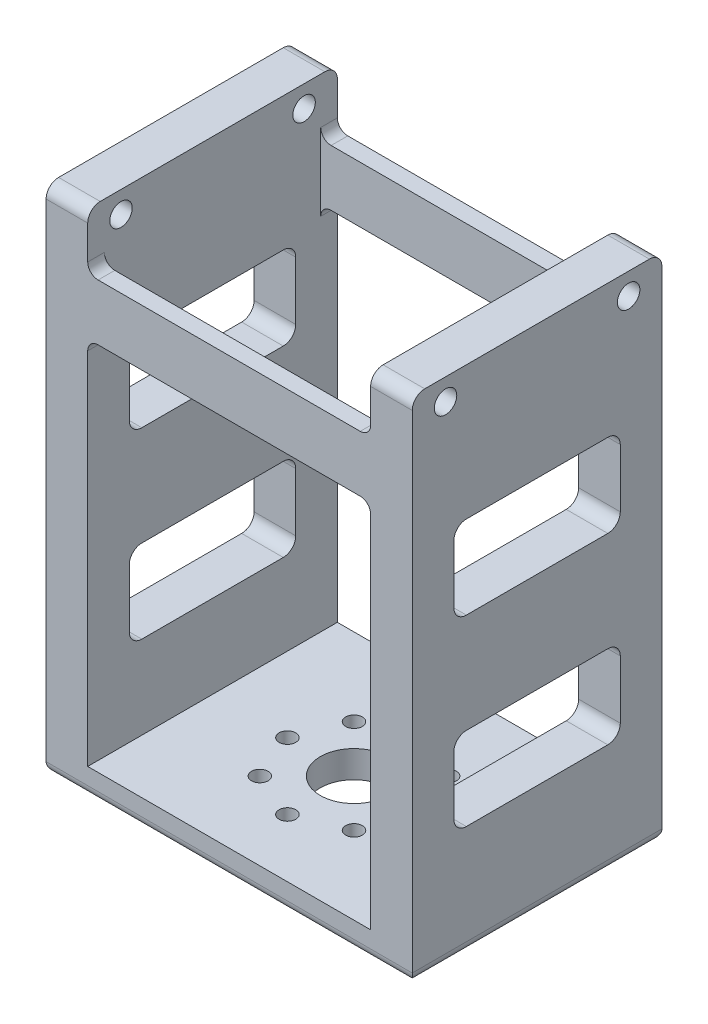
from build123d import *

# Parameters (mm, degrees)
SKETCH1_W            = 44
SKETCH1_H            = 30
BOSS_EXTRUDE1_DEPTH  = 54.5
SKETCH5_W            = 5
SKETCH5_H            = 30
BOSS_EXTRUDE3_DEPTH  = 6.8
SKETCH9_R            = 1.35
CUT_EXTRUDE6_DEPTH   = 79.604643629
FILLET1_R            = 1.5
FILLET2_R            = 1.25
SKETCH11_W           = 34
SKETCH11_H           = 26
CUT_EXTRUDE7_DEPTH   = 51.25
CUT_EXTRUDE8_REACH   = 83.202
SKETCH13_R           = 4.05
SKETCH13_R_2         = 1
CIRPATTERN1_COUNT    = 8
CUT_EXTRUDE10_REACH  = 83.202
SKETCH15_W           = 20
SKETCH15_H           = 10
FILLET6_R            = 1.5
FILLET6_OF_MIRROR4_R = 1.5
CUT_EXTRUDE11_REACH  = 83.202
SKETCH16_W           = 34
SKETCH16_H           = 44.5
FILLET7_R            = 1.25


with BuildPart() as part:
    # Sketch1 → Boss-Extrude1 (new body)
    with BuildSketch(Plane(origin=(0, 0, 0), x_dir=(1, 0, 0), z_dir=(0, 1, 0))):
        with Locations((22, 15)):
            Rectangle(SKETCH1_W, SKETCH1_H)
    extrude(amount=BOSS_EXTRUDE1_DEPTH)

    # Sketch5 → Boss-Extrude3 (add)
    with BuildSketch(Plane(origin=(0, 54.5, 0), x_dir=(1, 0, 0), z_dir=(0, 1, 0))):
        with Locations((2.5, 15)):
            Rectangle(SKETCH5_W, SKETCH5_H)
    boss_extrude3 = extrude(amount=BOSS_EXTRUDE3_DEPTH)

    # Sketch9 → Cut-Extrude6 (cut, through all)
    with BuildSketch(Plane(origin=(5, 0, 0), x_dir=(0, 0, -1), z_dir=(1, 0, 0))):
        with Locations((26, 58.7)):
            Circle(SKETCH9_R)
        with Locations((4, 58.7)):
            Circle(SKETCH9_R)
    cut_extrude6 = extrude(amount=-CUT_EXTRUDE6_DEPTH, mode=Mode.SUBTRACT)

    # Mirror2: Boss-Extrude3, Cut-Extrude6 across plane
    add(boss_extrude3.mirror(Plane.ZY.offset(-22)))
    add(cut_extrude6.mirror(Plane.ZY.offset(-22)), mode=Mode.SUBTRACT)

    # Fillet1
    fillet1_edges = [part.edges().sort_by_distance(p)[0] for p in [
        (41.5, 61.3, -30),
        (2.5, 61.3, -30),
        (2.5, 61.3, 0),
        (41.5, 61.3, 0),
    ]]
    fillet(fillet1_edges, radius=FILLET1_R)

    # Fillet2
    fillet2_edges = [part.edges().sort_by_distance(p)[0] for p in [
        (0, 0, -15),
        (22, 0, -30),
        (22, 0, 0),
        (44, 0, -15),
    ]]
    fillet(fillet2_edges, radius=FILLET2_R)

    # Sketch11 → Cut-Extrude7 (cut)
    with BuildSketch(Plane(origin=(0, 54.5, 0), x_dir=(1, 0, 0), z_dir=(0, 1, 0))):
        with Locations((22, 15)):
            Rectangle(SKETCH11_W, SKETCH11_H)
    extrude(amount=-CUT_EXTRUDE7_DEPTH, mode=Mode.SUBTRACT)

    # Sketch13 → Cut-Extrude8 (cut, up to next)
    with BuildSketch(Plane.XZ, mode=Mode.PRIVATE) as cut_extrude8_sk1:
        with Locations((22, -15)):
            Circle(SKETCH13_R)
    cut_extrude8_tool1 = extrude(cut_extrude8_sk1.sketch, amount=-CUT_EXTRUDE8_REACH, mode=Mode.PRIVATE) & part.part
    # Sketch13 → Cut-Extrude8 (cut, up to next)
    with BuildSketch(Plane.XZ, mode=Mode.PRIVATE) as cut_extrude8_sk2:
        with Locations((30, -15)):
            Circle(SKETCH13_R_2)
    cut_extrude8_tool2 = extrude(cut_extrude8_sk2.sketch, amount=-CUT_EXTRUDE8_REACH, mode=Mode.PRIVATE) & part.part
    cut_extrude8_1 = cut_extrude8_tool1.solids().sort_by_distance((22, 0, -15))[0]
    add(cut_extrude8_1, mode=Mode.SUBTRACT)
    cut_extrude8_2 = cut_extrude8_tool2.solids().sort_by_distance((30, 0, -15))[0]
    add(cut_extrude8_2, mode=Mode.SUBTRACT)
    cut_extrude8 = cut_extrude8_1 + cut_extrude8_2  # Cut-Extrude8 as one shape, for the pattern or mirror that repeats it

    # CirPattern1: Cut-Extrude8 ×8 about axis
    cirpattern1_axis = Axis((22, 0, -15), (0, -1, 0))
    for i in range(1, CIRPATTERN1_COUNT):
        add(cut_extrude8.rotate(cirpattern1_axis, i * 360 / CIRPATTERN1_COUNT), mode=Mode.SUBTRACT)

    # Sketch15 → Cut-Extrude10 (cut, up to next)
    with BuildSketch(Plane(origin=(44, 0, 0), x_dir=(0, 0, -1), z_dir=(1, 0, 0)), mode=Mode.PRIVATE) as cut_extrude10_sk1:
        with Locations((15, 18.25)):
            Rectangle(SKETCH15_W, SKETCH15_H)
    cut_extrude10_tool1 = extrude(cut_extrude10_sk1.sketch, amount=-CUT_EXTRUDE10_REACH, mode=Mode.PRIVATE) & part.part
    # Sketch15 → Cut-Extrude10 (cut, up to next)
    with BuildSketch(Plane(origin=(44, 0, 0), x_dir=(0, 0, -1), z_dir=(1, 0, 0)), mode=Mode.PRIVATE) as cut_extrude10_sk2:
        with Locations((15, 40.25)):
            Rectangle(SKETCH15_W, SKETCH15_H)
    cut_extrude10_tool2 = extrude(cut_extrude10_sk2.sketch, amount=-CUT_EXTRUDE10_REACH, mode=Mode.PRIVATE) & part.part
    cut_extrude10_1 = cut_extrude10_tool1.solids().sort_by_distance((44, 18.25, -15))[0]
    add(cut_extrude10_1, mode=Mode.SUBTRACT)
    cut_extrude10_2 = cut_extrude10_tool2.solids().sort_by_distance((44, 40.25, -15))[0]
    add(cut_extrude10_2, mode=Mode.SUBTRACT)
    cut_extrude10 = cut_extrude10_1 + cut_extrude10_2  # Cut-Extrude10 as one shape, for the pattern or mirror that repeats it

    # Fillet6
    fillet6_edges = [part.edges().sort_by_distance(p)[0] for p in [
        (41.5, 13.25, -5),
        (41.5, 35.25, -5),
        (41.5, 23.25, -5),
        (41.5, 45.25, -5),
        (41.5, 23.25, -25),
        (41.5, 45.25, -25),
        (41.5, 35.25, -25),
        (41.5, 13.25, -25),
    ]]
    fillet(fillet6_edges, radius=FILLET6_R)

    # Mirror4: Cut-Extrude10 across plane
    add(cut_extrude10.mirror(Plane.ZY.offset(-22)), mode=Mode.SUBTRACT)

    # Fillet6 of Mirror4
    fillet6_of_mirror4_edges = [part.edges().sort_by_distance(p)[0] for p in [
        (2.5, 13.25, -5),
        (2.5, 35.25, -5),
        (2.5, 23.25, -5),
        (2.5, 45.25, -5),
        (2.5, 23.25, -25),
        (2.5, 45.25, -25),
        (2.5, 35.25, -25),
        (2.5, 13.25, -25),
    ]]
    fillet(fillet6_of_mirror4_edges, radius=FILLET6_OF_MIRROR4_R)

    # Sketch16 → Cut-Extrude11 (cut, up to next)
    with BuildSketch(Plane.XY, mode=Mode.PRIVATE) as cut_extrude11_sk1:
        with Locations((22, 25.5)):
            Rectangle(SKETCH16_W, SKETCH16_H)
    cut_extrude11_tool1 = extrude(cut_extrude11_sk1.sketch, amount=-CUT_EXTRUDE11_REACH, mode=Mode.PRIVATE) & part.part
    cut_extrude11 = cut_extrude11_tool1.solids().sort_by_distance((22, 25.5, 0))[0]
    add(cut_extrude11, mode=Mode.SUBTRACT)

    # Mirror5: Cut-Extrude11 across plane
    add(cut_extrude11.mirror(Plane(origin=(0, 0, -15), x_dir=(1, 0, 0), z_dir=(0, 0, -1))), mode=Mode.SUBTRACT)

    # Fillet7
    fillet7_edges = [part.edges().sort_by_distance(p)[0] for p in [
        (5, 47.75, -29),
        (5, 47.75, -1),
        (5, 54.5, -1),
        (5, 54.5, -29),
        (39, 54.5, -1),
        (39, 54.5, -29),
        (39, 47.75, -29),
        (39, 47.75, -1),
    ]]
    fillet(fillet7_edges, radius=FILLET7_R)


solid = part.part
